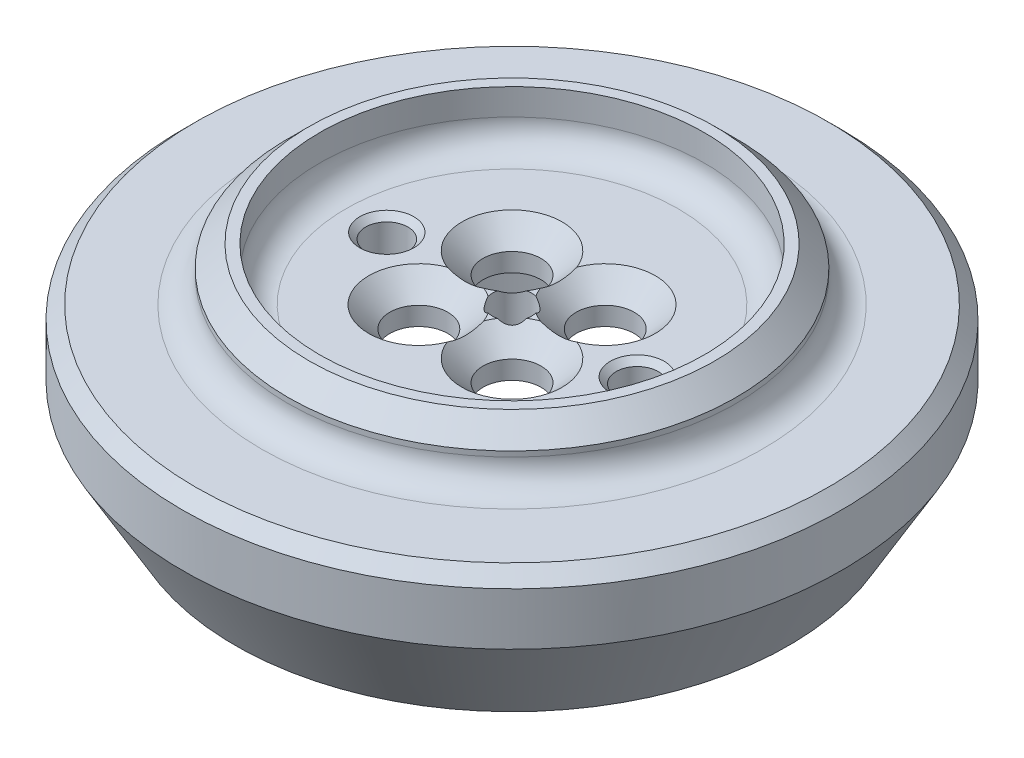
from build123d import *

# Parameters (mm, degrees)
SKETCH1_R                                       = 12.5
BOSS_EXTRUDE1_DEPTH                             = 1.5
SKETCH2_R                                       = 0.75
CUT_EXTRUDE1_DEPTH                              = 1
CUT_EXTRUDE1_DEPTH_BACK                         = 2.5
CSK_FOR_M2_FLAT_HEAD_MACHINE_SCREW1_D           = 2.2
CSK_FOR_M2_FLAT_HEAD_MACHINE_SCREW1_DEPTH       = 5
CSK_FOR_M2_FLAT_HEAD_MACHINE_SCREW1_CSINK_D     = 3.8
CSK_FOR_M2_FLAT_HEAD_MACHINE_SCREW1_CSINK_ANGLE = 90
CSK_FOR_M2_FLAT_HEAD_MACHINE_SCREW1_TIP         = 0.660946681
SKETCH7_R                                       = 12.5
SKETCH7_R_2                                     = 7.05
BOSS_EXTRUDE2_DEPTH                             = 3.3
SKETCH15_R                                      = 8.5
SKETCH15_R_2                                    = 7.3
BOSS_EXTRUDE4_DEPTH                             = 2
FILLET1_R                                       = 1
CHAMFER1_SIZE                                   = 0.5
CHAMFER2_SIZE                                   = 1
CHAMFER3_SIZE                                   = 2
CHAMFER3_SIZE2                                  = 3.464101615
M2X0_4_TAPPED_HOLE1_D                           = 1.6
M2X0_4_TAPPED_HOLE1_DEPTH                       = 5.2
M2X0_4_TAPPED_HOLE1_CSINK_D                     = 2.05
M2X0_4_TAPPED_HOLE1_CSINK_ANGLE                 = 90
M2X0_4_TAPPED_HOLE1_TIP                         = 0.480688495
CHAMFER4_SIZE                                   = 0.8


with BuildPart() as part:
    # Sketch1 → Boss-Extrude1 (new body)
    with BuildSketch(Plane(origin=(0, 0, 0), x_dir=(1, 0, 0), z_dir=(0, 1, 0))):
        Circle(SKETCH1_R)
    extrude(amount=BOSS_EXTRUDE1_DEPTH)

    # Sketch2 → Cut-Extrude1 (cut, two sides)
    with BuildSketch(Plane(origin=(0, 1.5, 0), x_dir=(1, 0, 0), z_dir=(0, 1, 0))) as cut_extrude1_sk:
        Circle(SKETCH2_R)
    extrude(amount=CUT_EXTRUDE1_DEPTH, mode=Mode.SUBTRACT)
    extrude(cut_extrude1_sk.sketch, amount=-CUT_EXTRUDE1_DEPTH_BACK, mode=Mode.SUBTRACT)

    # CSK for M2 Flat Head Machine Screw1
    with Locations(Plane(origin=(0, 1.5, 0), x_dir=(1, 0, 0), z_dir=(0, 1, 0))):
        with Locations((-1.767766953, 1.767766953), (1.767766953, 1.767766953), (1.767766953, -1.767766953), (-1.767766953, -1.767766953)):
            CounterSinkHole(CSK_FOR_M2_FLAT_HEAD_MACHINE_SCREW1_D / 2, CSK_FOR_M2_FLAT_HEAD_MACHINE_SCREW1_CSINK_D / 2, depth=CSK_FOR_M2_FLAT_HEAD_MACHINE_SCREW1_DEPTH, counter_sink_angle=CSK_FOR_M2_FLAT_HEAD_MACHINE_SCREW1_CSINK_ANGLE)
            with Locations((0, 0, -(CSK_FOR_M2_FLAT_HEAD_MACHINE_SCREW1_DEPTH + CSK_FOR_M2_FLAT_HEAD_MACHINE_SCREW1_TIP / 2))):  # 118° drill point
                Cone(0, CSK_FOR_M2_FLAT_HEAD_MACHINE_SCREW1_D / 2, CSK_FOR_M2_FLAT_HEAD_MACHINE_SCREW1_TIP, mode=Mode.SUBTRACT)

    # Sketch6 → Revolve1 (revolve)
    with BuildSketch(Plane.XY):
        Polygon((-12.5, 0), (-12.5, -1.15), (-7.05, -1.15), (-5, 0), align=None)
    revolve(axis=Axis((0, 0, 0), (0, -1, 0)))

    # Sketch7 → Boss-Extrude2 (add)
    with BuildSketch(Plane.XZ.offset(1.15)):
        Circle(SKETCH7_R)
        Circle(SKETCH7_R_2, mode=Mode.SUBTRACT)
    extrude(amount=BOSS_EXTRUDE2_DEPTH)

    # Sketch15 → Boss-Extrude4 (add)
    with BuildSketch(Plane(origin=(0, 1.5, 0), x_dir=(1, 0, 0), z_dir=(0, 1, 0))):
        Circle(SKETCH15_R)
        Circle(SKETCH15_R_2, mode=Mode.SUBTRACT)
    extrude(amount=BOSS_EXTRUDE4_DEPTH)

    # Fillet1
    fillet1_edges = [part.edges().sort_by_distance(p)[0] for p in [
        (0, -1.15, 7.05),
        (5, 0, 0),
        (-7.3, 1.5, 0),
        (-8.5, 1.5, 0),
    ]]
    fillet(fillet1_edges, radius=FILLET1_R)

    # Chamfer1
    chamfer1_edges = [part.edges().sort_by_distance(p)[0] for p in [
        (-12.5, 1.5, 0),
    ]]
    chamfer(chamfer1_edges, length=CHAMFER1_SIZE)

    # Chamfer2
    chamfer2_edges = [part.edges().sort_by_distance(p)[0] for p in [
        (-7.05, -4.45, 0),
    ]]
    chamfer(chamfer2_edges, length=CHAMFER2_SIZE)

    # Chamfer3
    chamfer3_edges = [part.edges().sort_by_distance(p)[0] for p in [
        (-12.5, -4.45, 0),
    ]]
    chamfer3_side = [part.faces().sort_by_distance(p)[0] for p in [
        (-8.403553391, -4.45, 0),
    ]]
    chamfer(chamfer3_edges, length=CHAMFER3_SIZE, length2=CHAMFER3_SIZE2, reference=chamfer3_side[0])

    # M2x0.4 Tapped Hole1
    with Locations(Plane(origin=(0, 1.5, 0), x_dir=(1, 0, 0), z_dir=(0, 1, 0))):
        with Locations((-4.75, 0), (4.75, 0)):
            CounterSinkHole(M2X0_4_TAPPED_HOLE1_D / 2, M2X0_4_TAPPED_HOLE1_CSINK_D / 2, depth=M2X0_4_TAPPED_HOLE1_DEPTH, counter_sink_angle=M2X0_4_TAPPED_HOLE1_CSINK_ANGLE)
            with Locations((0, 0, -(M2X0_4_TAPPED_HOLE1_DEPTH + M2X0_4_TAPPED_HOLE1_TIP / 2))):  # 118° drill point
                Cone(0, M2X0_4_TAPPED_HOLE1_D / 2, M2X0_4_TAPPED_HOLE1_TIP, mode=Mode.SUBTRACT)

    # Chamfer4
    chamfer4_edges = [part.edges().sort_by_distance(p)[0] for p in [
        (-8.5, 3.5, 0),
    ]]
    chamfer(chamfer4_edges, length=CHAMFER4_SIZE)


solid = part.part
